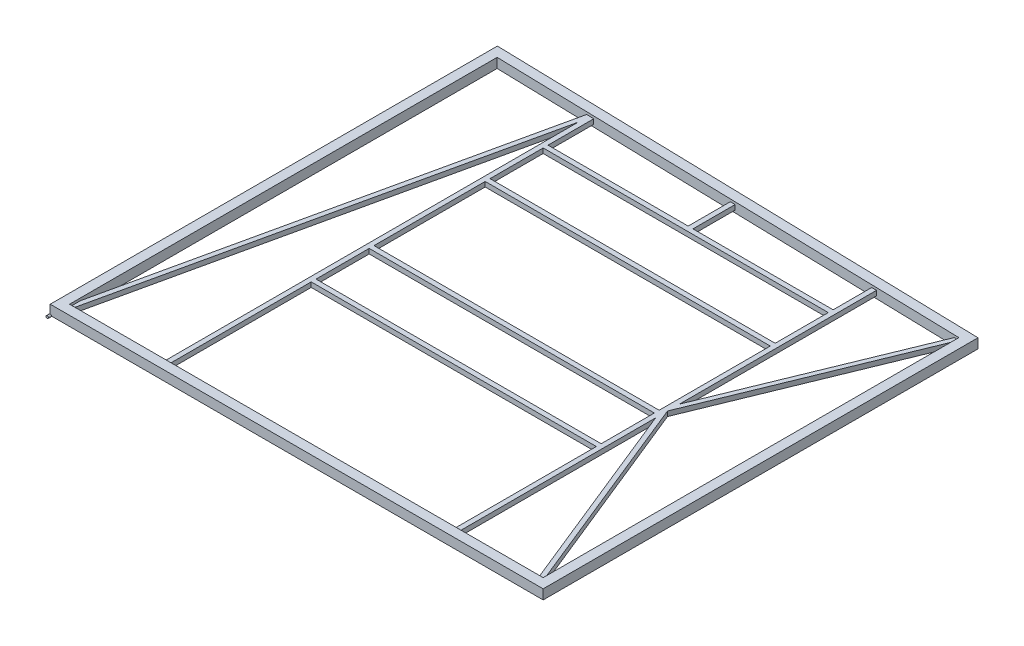
from build123d import *

# Parameters (mm, degrees)
SKETCH2_W           = 50.8
SKETCH2_H           = 50.8
SKETCH2_W_2         = 44.45
SKETCH2_H_2         = 44.45
BOSS_EXTRUDE1_REACH = 2301.343
SKETCH3_W           = 25.4
SKETCH3_H           = 25.4
SKETCH3_W_2         = 19.05
SKETCH3_H_2         = 19.05
SKETCH4_W           = 25.4
SKETCH4_H           = 25.4
SKETCH4_W_2         = 19.05
SKETCH4_H_2         = 19.05
BOSS_EXTRUDE2_DEPTH = 1498.6
SKETCH5_W           = 25.4
SKETCH5_H           = 25.4
SKETCH5_W_2         = 19.05
SKETCH5_H_2         = 19.05
BOSS_EXTRUDE3_REACH = 307.443
SKETCH11_W          = 25.4
SKETCH11_H          = 25.4
SKETCH11_W_2        = 19.05
SKETCH11_H_2        = 19.05
SKETCH13_W          = 25.4
SKETCH13_H          = 25.4
SKETCH13_W_2        = 19.05
SKETCH13_H_2        = 19.05
SKETCH15_R          = 6.35
BOSS_EXTRUDE4_DEPTH = 15.875
SKETCH16_R          = 6.35
BOSS_EXTRUDE5_DEPTH = 15.875


with BuildPart() as part:
    # Sweep1: sweep along a path in Sketch1
    with BuildLine(Plane(origin=(0, 0, 0), x_dir=(1, 0, 0), z_dir=(0, 1, 0))) as sweep1_path:
        Line((0, 2298.7), (0, 0))
        Line((0, 0), (2540, 0))
        Line((2540, 0), (2540, 2235.2))
        Line((2540, 2235.2), (0, 2298.7))
    # Sketch2 → Sweep1 (sweep)
    with BuildSketch(Plane.XY.offset(-1016)):
        Rectangle(SKETCH2_W, SKETCH2_H)
        Rectangle(SKETCH2_W_2, SKETCH2_H_2, mode=Mode.SUBTRACT)
    sweep(path=sweep1_path.line, transition=Transition.RIGHT)

    # Boss-Extrude1: up to this face of the body (flat: up to its plane)
    boss_extrude1_end = Plane(part.part.faces().sort_by_distance((1270, 0, -2241.54206374))[0])
    # Sketch3 → Boss-Extrude1 (add, up to the picked face)
    with BuildSketch(Plane(origin=(0, 0, -25.4), x_dir=(-1, 0, 0), z_dir=(0, 0, -1)), mode=Mode.PRIVATE) as boss_extrude1_sk1:
        with Locations((-533.4, 0)):
            Rectangle(SKETCH3_W, SKETCH3_H)
        with Locations((-533.4, 0)):
            Rectangle(SKETCH3_W_2, SKETCH3_H_2, mode=Mode.SUBTRACT)
    boss_extrude1_tool1 = split(extrude(boss_extrude1_sk1.sketch, amount=BOSS_EXTRUDE1_REACH, mode=Mode.PRIVATE), bisect_by=boss_extrude1_end, keep=Keep.BOTH, mode=Mode.PRIVATE)
    add(boss_extrude1_tool1.solids().sort_by_distance((521.05921, 0, -25.4))[0])
    # Sketch3 → Boss-Extrude1 (add, up to the picked face)
    with BuildSketch(Plane(origin=(0, 0, -25.4), x_dir=(-1, 0, 0), z_dir=(0, 0, -1)), mode=Mode.PRIVATE) as boss_extrude1_sk2:
        with Locations((-2057.4, 0)):
            Rectangle(SKETCH3_W, SKETCH3_H)
        with Locations((-2057.4, 0)):
            Rectangle(SKETCH3_W_2, SKETCH3_H_2, mode=Mode.SUBTRACT)
    boss_extrude1_tool2 = split(extrude(boss_extrude1_sk2.sketch, amount=BOSS_EXTRUDE1_REACH, mode=Mode.PRIVATE), bisect_by=boss_extrude1_end, keep=Keep.BOTH, mode=Mode.PRIVATE)
    add(boss_extrude1_tool2.solids().sort_by_distance((2057.4, -12.34079, -25.4))[0])

    # Sketch4 → Boss-Extrude2 (add)
    with BuildSketch(Plane(origin=(546.1, 0, 0), x_dir=(0, 0, -1), z_dir=(1, 0, 0))):
        with Locations((787.4, 0)):
            Rectangle(SKETCH4_W, SKETCH4_H)
        with Locations((787.4, 0)):
            Rectangle(SKETCH4_W_2, SKETCH4_H_2, mode=Mode.SUBTRACT)
        with Locations((1092.2, 0)):
            Rectangle(SKETCH4_W, SKETCH4_H)
        with Locations((1092.2, 0)):
            Rectangle(SKETCH4_W_2, SKETCH4_H_2, mode=Mode.SUBTRACT)
        with Locations((1701.8, 0)):
            Rectangle(SKETCH4_W, SKETCH4_H)
        with Locations((1701.8, 0)):
            Rectangle(SKETCH4_W_2, SKETCH4_H_2, mode=Mode.SUBTRACT)
        with Locations((2006.6, 0)):
            Rectangle(SKETCH4_W, SKETCH4_H)
        with Locations((2006.6, 0)):
            Rectangle(SKETCH4_W_2, SKETCH4_H_2, mode=Mode.SUBTRACT)
    extrude(amount=BOSS_EXTRUDE2_DEPTH)

    # Sweep2: sweep along a path in Sketch6
    with BuildLine(Plane(origin=(0, 25.4, 0), x_dir=(1, 0, 0), z_dir=(0, 1, 0))) as sweep2_path:
        Line((25.4, 25.4), (520.7, 2260.27456374))
    # Sketch5 → Sweep2 (sweep)
    with BuildSketch(Plane(origin=(0, 0, -25.4), x_dir=(-1, 0, 0), z_dir=(0, 0, -1))):
        with Locations((-25.4, 0)):
            Rectangle(SKETCH5_W, SKETCH5_H)
        with Locations((-25.4, 0)):
            Rectangle(SKETCH5_W_2, SKETCH5_H_2, mode=Mode.SUBTRACT)
    sweep(path=sweep2_path.line)

    # Boss-Extrude3: up to this face of the body (flat: up to its plane)
    boss_extrude3_end = Plane(part.part.faces().sort_by_distance((1269.73814433, 0, -2241.548610131))[0])
    # Sketch11 → Boss-Extrude3 (add, up to the picked face)
    with BuildSketch(Plane(origin=(0, 0, -2019.3), x_dir=(-1, 0, 0), z_dir=(0, 0, -1)), mode=Mode.PRIVATE) as boss_extrude3_sk1:
        with Locations((-1295.4, 0)):
            Rectangle(SKETCH11_W, SKETCH11_H)
        with Locations((-1295.4, 0)):
            Rectangle(SKETCH11_W_2, SKETCH11_H_2, mode=Mode.SUBTRACT)
    boss_extrude3_tool1 = split(extrude(boss_extrude3_sk1.sketch, amount=BOSS_EXTRUDE3_REACH, mode=Mode.PRIVATE), bisect_by=boss_extrude3_end, keep=Keep.BOTH, mode=Mode.PRIVATE)
    add(boss_extrude3_tool1.solids().sort_by_distance((1295.4, -12.34079, -2019.3))[0])

    # Sweep6: sweep along a path in Sketch14
    with BuildLine(Plane(origin=(0, 25.4, 0), x_dir=(1, 0, 0), z_dir=(0, 1, 0))) as sweep6_path:
        Line((2514.6, 25.4), (2070.1, 1123.46978187))
        Line((2070.1, 1123.46978187), (2514.6, 2210.42706374))
    # Sketch13 → Sweep6 (sweep)
    with BuildSketch(Plane(origin=(0, 0, -25.4), x_dir=(-1, 0, 0), z_dir=(0, 0, -1))):
        with Locations((-2501.9, 0)):
            Rectangle(SKETCH13_W, SKETCH13_H)
        with Locations((-2501.9, 0)):
            Rectangle(SKETCH13_W_2, SKETCH13_H_2, mode=Mode.SUBTRACT)
    sweep(path=sweep6_path.line, transition=Transition.RIGHT)

    # Sketch15 → Boss-Extrude4 (add, symmetric)
    with BuildSketch(Plane.XY.offset(-2324.74293626)):
        with Locations((-25.4, -25.4)):
            Circle(SKETCH15_R)
    extrude(amount=BOSS_EXTRUDE4_DEPTH, both=True)

    # Sketch16 → Boss-Extrude5 (add, symmetric)
    with BuildSketch(Plane.XY.offset(25.4)):
        with Locations((-25.4, -25.4)):
            Circle(SKETCH16_R)
    extrude(amount=BOSS_EXTRUDE5_DEPTH, both=True)


solid = part.part
